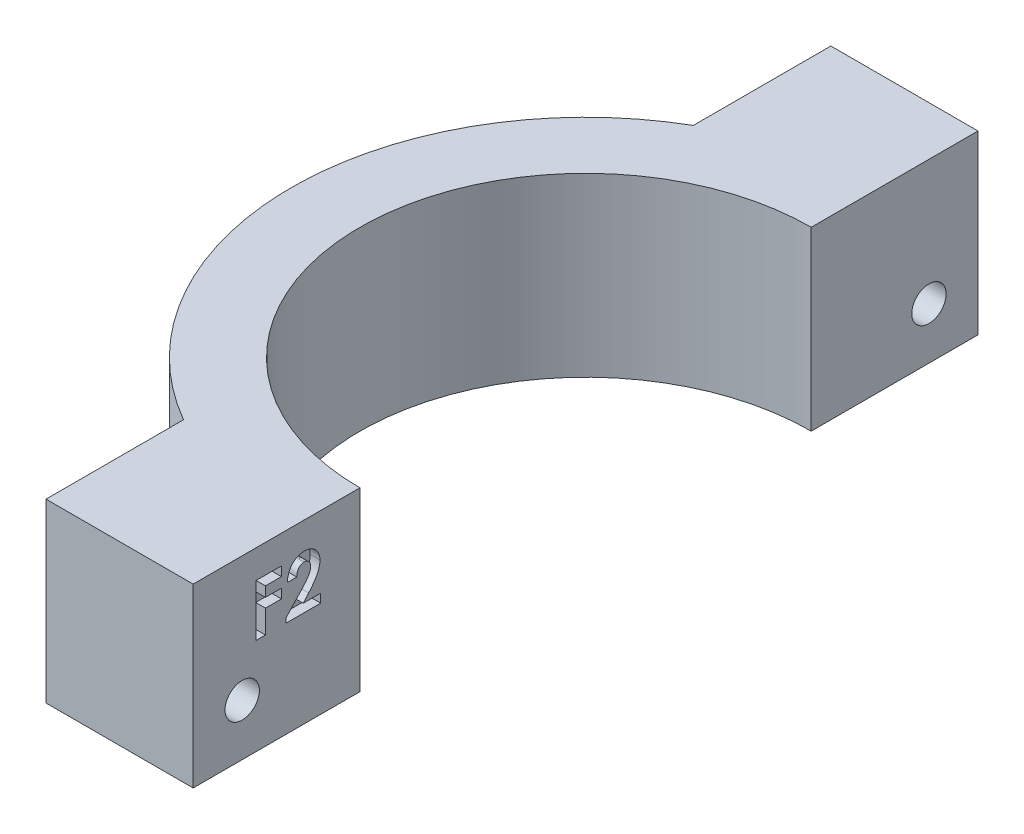
from build123d import *

# Parameters (mm, degrees)
BOSS_EXTRUDE1_DEPTH = 18
SKETCH2_R           = 1.75
CUT_EXTRUDE1_DEPTH  = 31
CUT_EXTRUDE2_DEPTH  = 1
CUT_EXTRUDE3_DEPTH  = 5


with BuildPart() as part:
    # Sketch1 → Boss-Extrude1 (new body)
    with BuildSketch(Plane(origin=(0, 0, 0), x_dir=(1, 0, 0), z_dir=(0, 1, 0))):
        with BuildLine():
            ThreePointArc((-31.998275301, 18.509333542), (-46.998275301, -7.471428571), (-31.998275301, -33.452190685))
            Line((-31.998275301, -33.452190685), (-31.998275301, -47.471428571))
            Line((-31.998275301, -47.471428571), (-16.998275301, -47.471428571))
            Line((-16.998275301, -47.471428571), (-16.998275301, -30.471428571))
            ThreePointArc((-16.998275301, -30.471428571), (-39.998275301, -7.471428571), (-16.998275301, 15.528571429))
            Line((-16.998275301, 15.528571429), (-16.998275301, 32.528571429))
            Line((-16.998275301, 32.528571429), (-31.998275301, 32.528571429))
            Line((-31.998275301, 32.528571429), (-31.998275301, 18.509333542))
        make_face()
    extrude(amount=BOSS_EXTRUDE1_DEPTH)

    # Sketch2 → Cut-Extrude1 (cut, through all)
    with BuildSketch(Plane(origin=(-16.998275301, 0, 0), x_dir=(0, 0, -1), z_dir=(1, 0, 0))):
        with Locations((-42.471428571, 5.25)):
            Circle(SKETCH2_R)
        with Locations((27.528571429, 5.25)):
            Circle(SKETCH2_R)
    extrude(amount=-CUT_EXTRUDE1_DEPTH, mode=Mode.SUBTRACT)

    # Sketch3 → Cut-Extrude2 (cut)
    with BuildSketch(Plane(origin=(-16.998275301, 0, 0), x_dir=(0, 0, -1), z_dir=(1, 0, 0))):
        Polygon((-41.052726264, 15.110089197), (-38.474734811, 15.110089197), (-38.474734811, 14.160302873), (-40.102939939, 14.160302873), (-40.102939939, 13.142674667), (-38.474734811, 13.142674667), (-38.474734811, 12.192888343), (-40.102939939, 12.192888343), (-40.102939939, 9.818422531), (-41.052726264, 9.818422531), align=None)
        with BuildLine():
            Line((-36.914371563, 13.346200308), (-37.864157888, 13.346200308))
            add(Edge.make_bspline(
                [(-37.864157888, 13.346200308), (-37.860055906, 13.418046619), (-37.852040881, 13.558429997), (-37.820159135, 13.762341347), (-37.77743869, 13.955015151), (-37.720422585, 14.135777413), (-37.648778118, 14.304562451), (-37.564348886, 14.461945662), (-37.464977915, 14.60709842), (-37.352780144, 14.739320716), (-37.229660384, 14.857938558), (-37.098174722, 14.963112588), (-36.956311907, 15.049899551), (-36.806663889, 15.121317187), (-36.64925615, 15.178376559), (-36.482599366, 15.216525367), (-36.30813654, 15.242360114), (-36.188702609, 15.244620758), (-36.127829763, 15.245772958)],
                knots=[0, 0, 0, 0, 0.000215773, 0.000421607, 0.000618333, 0.000807411, 0.000989332, 0.001167669, 0.001342317, 0.001516048, 0.001686973, 0.001854511, 0.002020137, 0.00218466, 0.002351301, 0.002521253, 0.002696799, 0.002879275, 0.002879275, 0.002879275, 0.002879275], degree=3))
            add(Edge.make_bspline(
                [(-36.127829763, 15.245772958), (-36.053109208, 15.24344148), (-35.907237174, 15.238889888), (-35.695273537, 15.200063297), (-35.497322677, 15.135119825), (-35.313528483, 15.044376667), (-35.145455629, 14.929096996), (-34.993131985, 14.791644856), (-34.861164061, 14.629136428), (-34.748715142, 14.448333423), (-34.65528353, 14.256888487), (-34.589810548, 14.058926484), (-34.546775862, 13.859700523), (-34.542185946, 13.725551844), (-34.539905751, 13.658908976)],
                knots=[0, 0, 0, 0, 0.000224028, 0.000437354, 0.000643845, 0.000847219, 0.001050092, 0.001253455, 0.001460573, 0.001675861, 0.00189111, 0.002097935, 0.002300212, 0.002499903, 0.002499903, 0.002499903, 0.002499903], degree=3))
            add(Edge.make_bspline(
                [(-34.539905751, 13.658908976), (-34.540793539, 13.618598659), (-34.542580436, 13.537463948), (-34.555004968, 13.414687217), (-34.573644221, 13.289624762), (-34.601747672, 13.162383812), (-34.63679498, 13.032928701), (-34.679312431, 12.900872012), (-34.730286257, 12.76696246), (-34.788865811, 12.629692915), (-34.858751366, 12.488617716), (-34.940123382, 12.341622092), (-35.035141655, 12.188836439), (-35.142658484, 12.02939808), (-35.263196054, 11.863558473), (-35.397342788, 11.69181718), (-35.543553632, 11.513569038), (-35.64732358, 11.394420158), (-35.700637923, 11.333204515)],
                knots=[0, 0, 0, 0, 0.000120918, 0.000243377, 0.000369908, 0.000500063, 0.000634034, 0.000772147, 0.000916066, 0.001063745, 0.001219713, 0.001388155, 0.0015676, 0.00175929, 0.00196496, 0.002182512, 0.002412975, 0.002656496, 0.002656496, 0.002656496, 0.002656496], degree=3))
            Line((-35.700637923, 11.333204515), (-36.25291323, 10.700366975))
            Line((-36.25291323, 10.700366975), (-34.472063871, 10.700366975))
            Line((-34.472063871, 10.700366975), (-34.472063871, 9.818422531))
            Line((-34.472063871, 9.818422531), (-37.999841648, 9.818422531))
            Line((-37.999841648, 9.818422531), (-37.999841648, 10.299675869))
            Line((-37.999841648, 10.299675869), (-36.433118224, 11.967102085))
            add(Edge.make_bspline(
                [(-36.433118224, 11.967102085), (-36.387757555, 12.015741425), (-36.299907391, 12.109941403), (-36.17490566, 12.248284093), (-36.061790136, 12.379568004), (-35.962906361, 12.505191043), (-35.873065041, 12.621078512), (-35.796272194, 12.730723404), (-35.731825226, 12.833134488), (-35.661858901, 12.956624369), (-35.595413893, 13.103908028), (-35.534446576, 13.273584842), (-35.497282777, 13.435756798), (-35.492152997, 13.541431531), (-35.489692076, 13.592127125)],
                knots=[0, 0, 0, 0, 0.000199522, 0.000386415, 0.00055934, 0.00071926, 0.000865974, 0.000999188, 0.001120653, 0.001228864, 0.001424763, 0.001604456, 0.001769334, 0.001921366, 0.001921366, 0.001921366, 0.001921366], degree=3))
            add(Edge.make_bspline(
                [(-35.489692076, 13.592127125), (-35.491532047, 13.641171201), (-35.495097287, 13.736201961), (-35.534276384, 13.871382712), (-35.594974, 13.993775082), (-35.680505512, 14.09972185), (-35.784110962, 14.186785334), (-35.903836792, 14.251540708), (-36.038706883, 14.288904261), (-36.133253387, 14.293580844), (-36.181891261, 14.295986633)],
                knots=[0, 0, 0, 0, 0.000146748, 0.000284348, 0.000418508, 0.000554258, 0.000689709, 0.000822026, 0.000959626, 0.001105406, 0.001105406, 0.001105406, 0.001105406], degree=3))
            add(Edge.make_bspline(
                [(-36.181891261, 14.295986633), (-36.207018207, 14.295097906), (-36.256484634, 14.293348303), (-36.329196415, 14.281701669), (-36.3983869, 14.261175694), (-36.464826215, 14.233673776), (-36.527805303, 14.197219786), (-36.587165312, 14.152284435), (-36.643531673, 14.100009634), (-36.696645869, 14.040558837), (-36.74498672, 13.974211731), (-36.787922888, 13.90157426), (-36.823423951, 13.822691512), (-36.854680377, 13.738604861), (-36.878786828, 13.648411147), (-36.896339316, 13.552650169), (-36.909683299, 13.451477719), (-36.912780379, 13.381931173), (-36.914371563, 13.346200308)],
                knots=[0, 0, 0, 0, 7.5381e-05, 0.0001484, 0.000220186, 0.000291452, 0.000363636, 0.000437838, 0.000514351, 0.000593931, 0.00067662, 0.000760248, 0.000846574, 0.00093578, 0.001029123, 0.001126213, 0.001227716, 0.001334967, 0.001334967, 0.001334967, 0.001334967], degree=3))
        make_face()
    extrude(amount=-CUT_EXTRUDE2_DEPTH, mode=Mode.SUBTRACT)

    # Sketch4 → Cut-Extrude3 (cut)
    with BuildSketch(Plane.ZY.offset(31.998275301)):
        Polygon((-25.735714731, 2.629122629), (-24.362396696, 5.49222076), (-26.155253394, 8.113098131), (-29.321428126, 7.870877371), (-30.694746161, 5.00777924), (-28.901889463, 2.386901869), align=None)
        Polygon((45.170887067, 3.577798708), (45.269326619, 6.751698988), (42.569868123, 8.42390028), (39.771970075, 6.922201292), (39.673530524, 3.748301012), (42.37298902, 2.07609972), align=None)
    extrude(amount=-CUT_EXTRUDE3_DEPTH, mode=Mode.SUBTRACT)


solid = part.part
